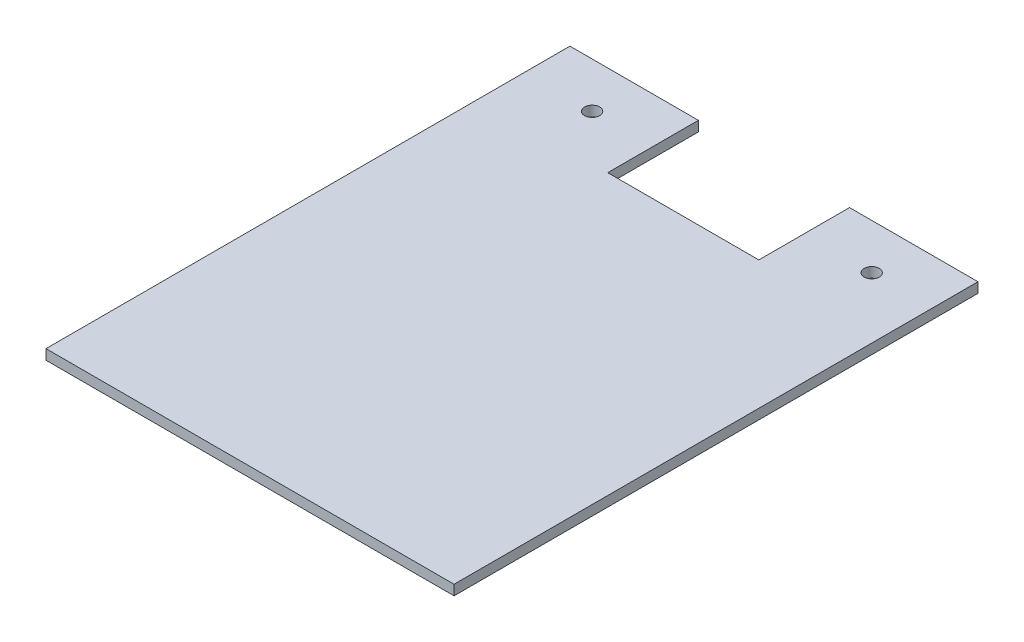
from build123d import *

# Parameters (mm, degrees)
SALIENTE_EXTRUIR1_DEPTH = 2
CROQUIS2_R              = 1.5
CORTAR_EXTRUIR1_DEPTH   = 2


with BuildPart() as part:
    # Croquis1 → Saliente-Extruir1 (new body)
    with BuildSketch(Plane(origin=(0, 0, 0), x_dir=(1, 0, 0), z_dir=(0, 1, 0))):
        Polygon((0, 0), (0, 104), (-25.5, 104), (-25.5, 86), (-55.5, 86), (-55.5, 104), (-81, 104), (-81, 0), align=None)
    extrude(amount=SALIENTE_EXTRUIR1_DEPTH)

    # Croquis2 → Cortar-Extruir1 (cut)
    with BuildSketch(Plane(origin=(0, 2, 0), x_dir=(1, 0, 0), z_dir=(0, 1, 0))):
        with Locations((-67.6, 95)):
            Circle(CROQUIS2_R)
        with Locations((-12.1, 95)):
            Circle(CROQUIS2_R)
    extrude(amount=-CORTAR_EXTRUIR1_DEPTH, mode=Mode.SUBTRACT)


solid = part.part
